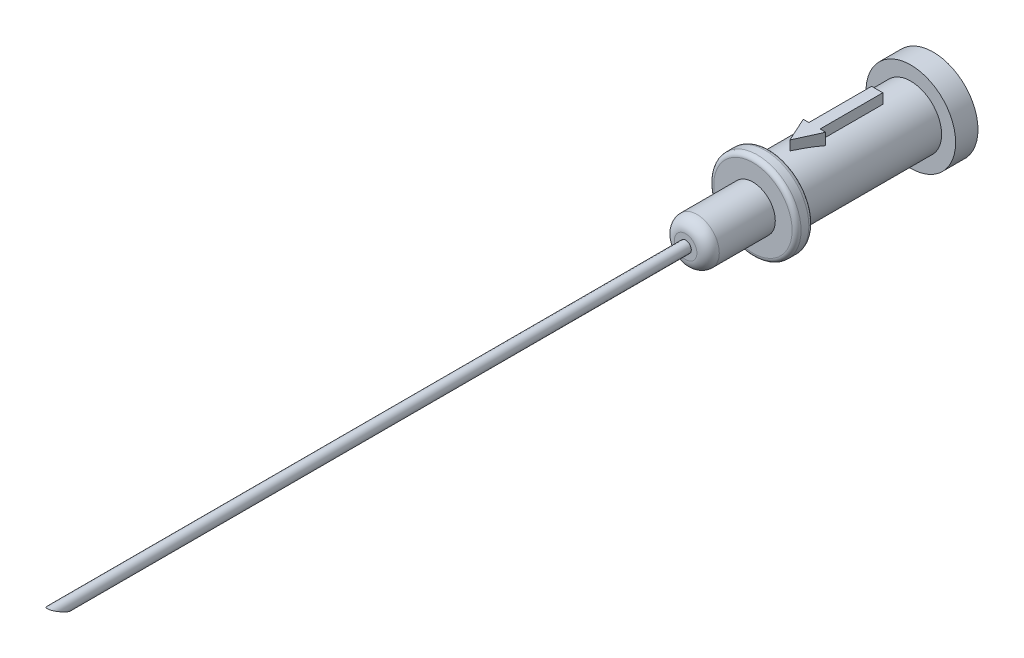
from build123d import *

# Parameters (mm, degrees)
SKETCH1_R               = 4
BOSS_EXTRUDE1_DEPTH     = 2
SKETCH2_R               = 2.75
BOSS_EXTRUDE2_DEPTH     = 12.6
SKETCH3_R               = 3.9
BOSS_EXTRUDE3_DEPTH     = 1.5
SKETCH4_R               = 2
BOSS_EXTRUDE4_DEPTH     = 6
FILLET1_R               = 1
BOSS_EXTRUDE5_DEPTH     = 3.6
SKETCH6_R               = 0.5
BOSS_EXTRUDE6_DEPTH     = 57
CUT_EXTRUDE1_DEPTH      = 5
CUT_EXTRUDE1_DEPTH_BACK = 5
FILLET2_R               = 0.4


with BuildPart() as part:
    # Sketch1 → Boss-Extrude1 (new body)
    with BuildSketch(Plane.XY):
        Circle(SKETCH1_R)
    extrude(amount=BOSS_EXTRUDE1_DEPTH)

    # Sketch2 → Boss-Extrude2 (add)
    with BuildSketch(Plane.XY.offset(2)):
        Circle(SKETCH2_R)
    extrude(amount=BOSS_EXTRUDE2_DEPTH)

    # Sketch3 → Boss-Extrude3 (add)
    with BuildSketch(Plane.XY.offset(14.6)):
        Circle(SKETCH3_R)
    extrude(amount=BOSS_EXTRUDE3_DEPTH)

    # Sketch4 → Boss-Extrude4 (add)
    with BuildSketch(Plane.XY.offset(16.1)):
        Circle(SKETCH4_R)
    extrude(amount=BOSS_EXTRUDE4_DEPTH)

    # Fillet1
    fillet1_edges = [part.edges().sort_by_distance(p)[0] for p in [
        (-2, 0, 22.1),
    ]]
    fillet(fillet1_edges, radius=FILLET1_R)

    # Sketch5 → Boss-Extrude5 (add)
    with BuildSketch(Plane(origin=(0, 0, 0), x_dir=(1, 0, 0), z_dir=(0, 1, 0))):
        Polygon((-0.5, -5), (0.5, -5), (0.5, -10.6), (1, -10.6), (0, -12.8), (-1, -10.6), (-0.5, -10.6), align=None)
    extrude(amount=BOSS_EXTRUDE5_DEPTH)

    # Sketch6 → Boss-Extrude6 (add)
    with BuildSketch(Plane.XY.offset(22.1)):
        Circle(SKETCH6_R)
    extrude(amount=BOSS_EXTRUDE6_DEPTH)

    # Sketch7 → Cut-Extrude1 (cut, two sides)
    with BuildSketch(Plane(origin=(0, 0, 0), x_dir=(0, 0, -1), z_dir=(1, 0, 0))) as cut_extrude1_sk:
        Polygon((-79.1, 0.5), (-77.1, -0.5), (-79.1, -0.5), align=None)
    extrude(amount=CUT_EXTRUDE1_DEPTH, mode=Mode.SUBTRACT)
    extrude(cut_extrude1_sk.sketch, amount=-CUT_EXTRUDE1_DEPTH_BACK, mode=Mode.SUBTRACT)

    # Fillet2
    fillet2_edges = [part.edges().sort_by_distance(p)[0] for p in [
        (-3.9, 0, 14.6),
        (-3.9, 0, 16.1),
    ]]
    fillet(fillet2_edges, radius=FILLET2_R)


solid = part.part
